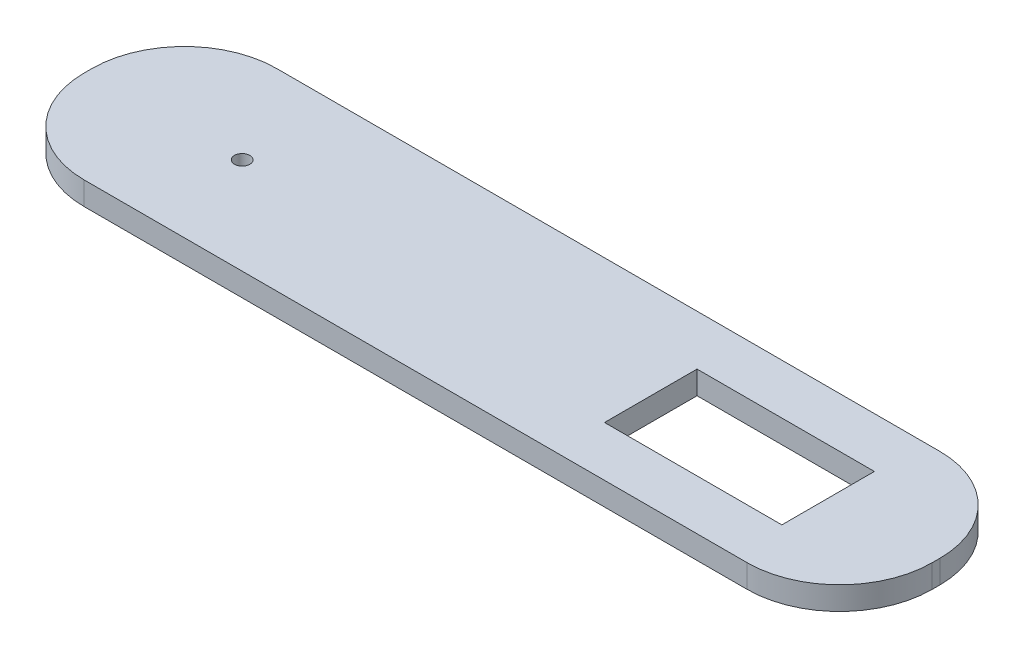
from build123d import *

# Parameters (mm, degrees)
SKETCH1_W           = 110
SKETCH1_H           = 25
BOSS_EXTRUDE1_DEPTH = 3
SKETCH2_W           = 23
SKETCH2_H           = 12
CUT_EXTRUDE1_DEPTH  = 4
SKETCH3_R           = 1
CUT_EXTRUDE2_DEPTH  = 4
FILLET1_R           = 12


with BuildPart() as part:
    # Sketch1 → Boss-Extrude1 (new body)
    with BuildSketch(Plane(origin=(0, 0, 0), x_dir=(1, 0, 0), z_dir=(0, 1, 0))):
        with Locations((55, 12.5)):
            Rectangle(SKETCH1_W, SKETCH1_H)
    extrude(amount=BOSS_EXTRUDE1_DEPTH)

    # Sketch2 → Cut-Extrude1 (cut, through all)
    with BuildSketch(Plane(origin=(0, 3, 0), x_dir=(1, 0, 0), z_dir=(0, 1, 0))):
        with Locations((84.5, 12.5)):
            Rectangle(SKETCH2_W, SKETCH2_H)
    extrude(amount=-CUT_EXTRUDE1_DEPTH, mode=Mode.SUBTRACT)

    # Sketch3 → Cut-Extrude2 (cut, through all)
    with BuildSketch(Plane(origin=(0, 3, 0), x_dir=(1, 0, 0), z_dir=(0, 1, 0))):
        with Locations((20, 12.5)):
            Circle(SKETCH3_R)
    extrude(amount=-CUT_EXTRUDE2_DEPTH, mode=Mode.SUBTRACT)

    # Fillet1
    fillet1_edges = [part.edges().sort_by_distance(p)[0] for p in [
        (0, 1.5, -25),
        (110, 1.5, -25),
        (110, 1.5, 0),
        (0, 1.5, 0),
    ]]
    fillet(fillet1_edges, radius=FILLET1_R)


solid = part.part
